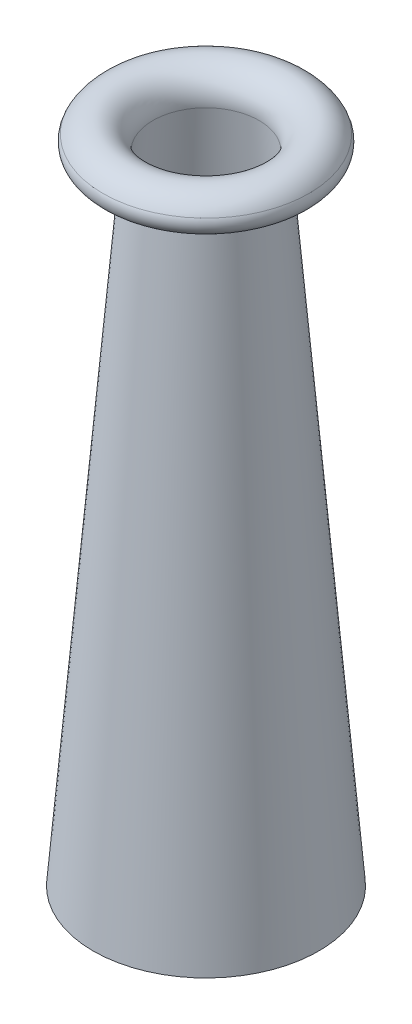
from build123d import *


with BuildPart() as part:
    # Sketch2 → Revolve1 (revolve)
    with BuildSketch(Plane.XY):
        with BuildLine():
            Line((-12.7, 49.406360504), (-25.4, -102.993639496))
            Line((-25.4, -102.993639496), (-26.994672522, -102.860750119))
            Line((-26.994672522, -102.860750119), (-14.294672522, 49.539249881))
            ThreePointArc((-14.294672522, 49.539249881), (-17.69059731, 54.501780923), (-23.238834198, 52.183141895))
            ThreePointArc((-23.238834198, 52.183141895), (-22.535453925, 50.143970387), (-20.556337766, 51.001911804))
            Line((-20.556337766, 51.001911804), (-19.04662806, 50.471424628))
            ThreePointArc((-19.04662806, 50.471424628), (-23.180342366, 48.679470834), (-24.64946942, 52.938620756))
            ThreePointArc((-24.64946942, 52.938620756), (-17.236981874, 56.036340494), (-12.7, 49.406360504))
        make_face()
    revolve(axis=Axis((0, 76.262194835, 0), (0, -1, 0)))


solid = part.part
